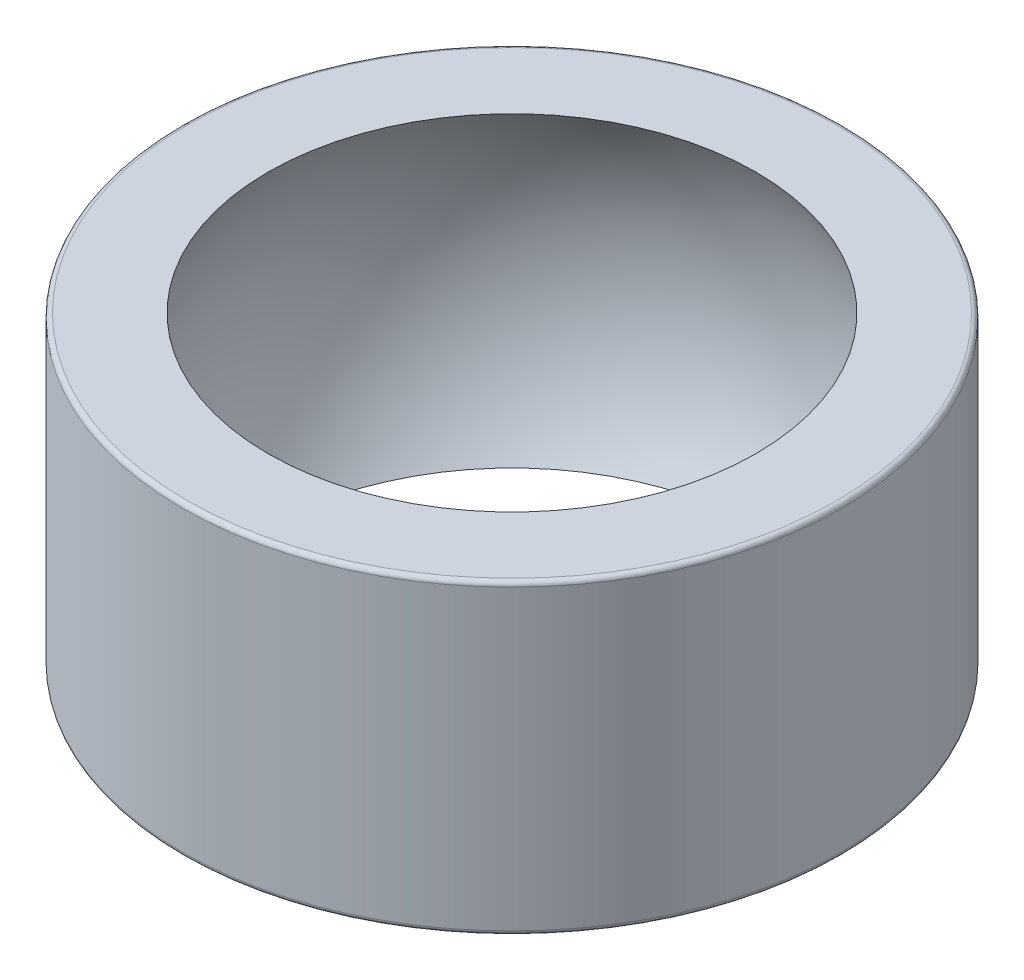
from build123d import *

# Parameters (mm, degrees)
SZKIC1_R                    = 14.5
DODANIE_WYCI_GNI_CIE1_DEPTH = 6.75
ZAOKR_GLENIE1_R             = 0.2


with BuildPart() as part:
    # Szkic1 → Dodanie-wyciągnięcie1 (new body, symmetric)
    with BuildSketch(Plane(origin=(0, 0, 0), x_dir=(1, 0, 0), z_dir=(0, 1, 0))):
        Circle(SZKIC1_R)
    extrude(amount=DODANIE_WYCI_GNI_CIE1_DEPTH, both=True)

    # Szkic3 → Wycięcie-obrót1 (revolve, cut)
    with BuildSketch(Plane.XY):
        with BuildLine():
            Line((0, -12.68), (0, 12.68))
            ThreePointArc((0, 12.68), (12.68, 0), (0, -12.68))
        make_face()
    revolve(axis=Axis((0, -12.68, 0), (0, 1, 0)), mode=Mode.SUBTRACT)

    # Zaokrąglenie1
    zaokr_glenie1_edges = [part.edges().sort_by_distance(p)[0] for p in [
        (-14.5, -6.75, 0),
        (-14.5, 6.75, 0),
    ]]
    fillet(zaokr_glenie1_edges, radius=ZAOKR_GLENIE1_R)


solid = part.part
